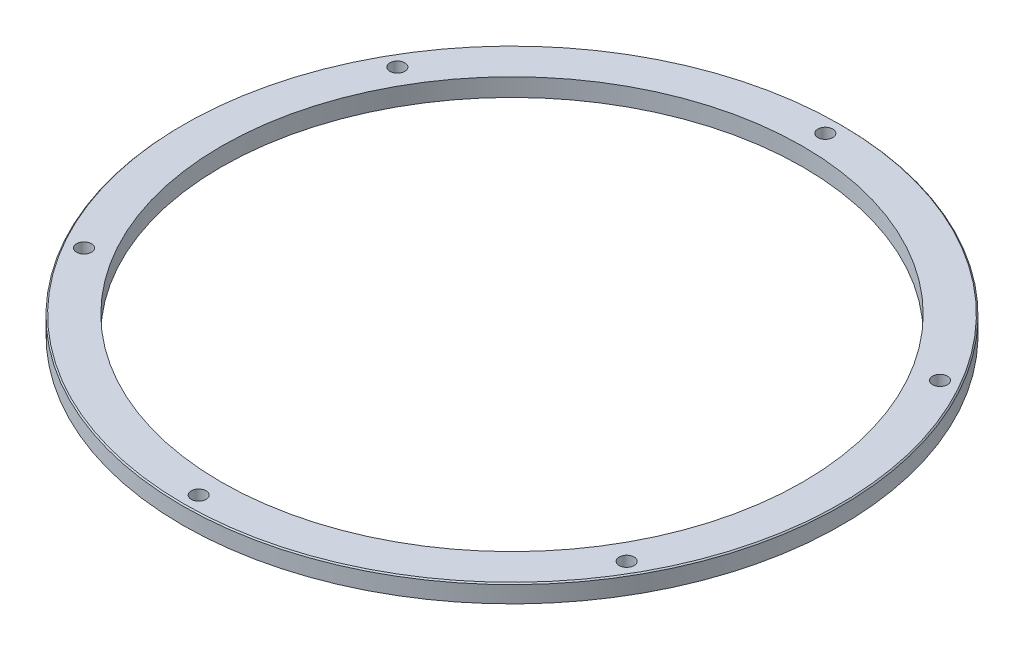
from build123d import *

# Parameters (mm, degrees)
SKETCH_1_R      = 55.25
SKETCH_1_R_2    = 48.75
EXTRUDE_1_DEPTH = 3
M3X0_5_1_D      = 2.5
CHAMFER_1_SIZE  = 0.2


with BuildPart() as part:
    # 草图1 → 凸台-拉伸1 (new body)
    with BuildSketch(Plane(origin=(0, 0, 0), x_dir=(1, 0, 0), z_dir=(0, 1, 0))):
        Circle(SKETCH_1_R)
        Circle(SKETCH_1_R_2, mode=Mode.SUBTRACT)
    extrude(amount=EXTRUDE_1_DEPTH)

    # M3x0.5 螺纹孔1 (through all)
    with Locations(Plane(origin=(0, 3, -52.525), x_dir=(0, 0, 1), z_dir=(0, 1, 0))):
        with Locations((0, 0), (26.2625, 45.487984334), (78.7875, 45.487984334), (105.05, 0), (78.7875, -45.487984334), (26.2625, -45.487984334)):
            Hole(M3X0_5_1_D / 2)

    # 倒角1
    chamfer_1_edges = [part.edges().sort_by_distance(p)[0] for p in [
        (-55.25, 3, 0),
    ]]
    chamfer(chamfer_1_edges, length=CHAMFER_1_SIZE)


solid = part.part
